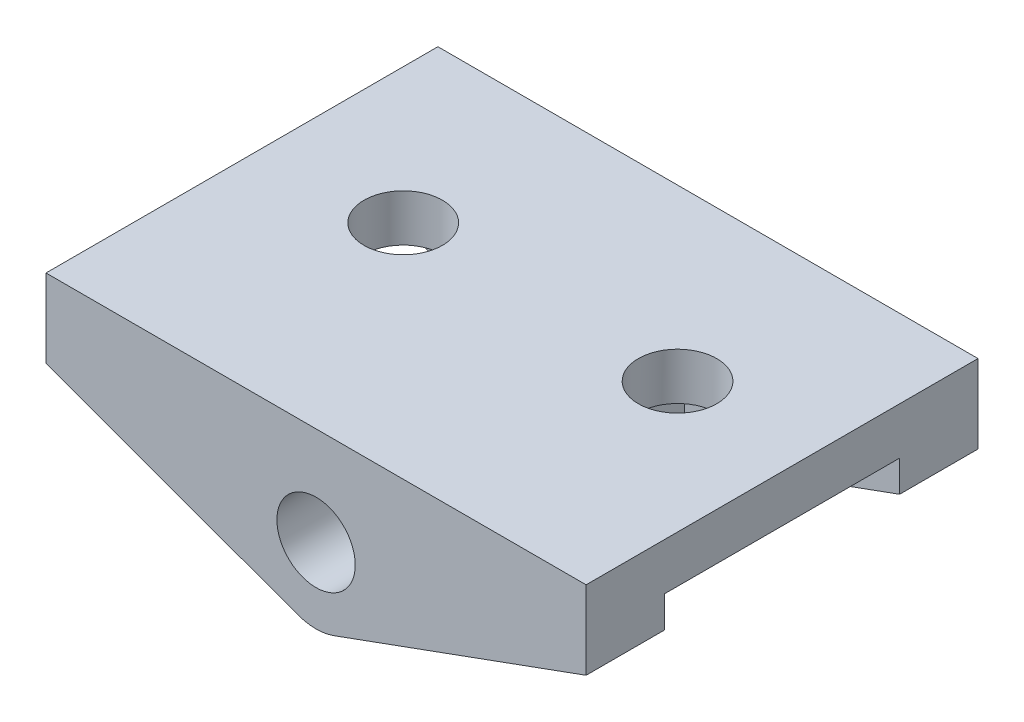
from build123d import *

# Parameters (mm, degrees)
CROQUIS2_R              = 1.5
SALIENTE_EXTRUIR2_DEPTH = 15
CROQUIS3_R              = 1.5
CORTAR_EXTRUIR1_DEPTH   = 7.633866032
CORTAR_EXTRUIR2_DEPTH   = 9
CORTAR_EXTRUIR3_DEPTH   = 9


with BuildPart() as part:
    # Croquis2 → Saliente-Extruir2 (new body)
    with BuildSketch(Plane.XY):
        with BuildLine():
            Line((-0.684040287, -2.751029697), (-10.336618829, 0.762221577))
            Line((-10.336618829, 0.762221577), (-10.336618829, 3.762221577))
            Line((-10.336618829, 3.762221577), (10.336618829, 3.762221577))
            Line((10.336618829, 3.762221577), (10.336618829, 0.762221577))
            Line((10.336618829, 0.762221577), (0.684040287, -2.751029697))
            ThreePointArc((0.684040287, -2.751029697), (0, -2.871644455), (-0.684040287, -2.751029697))
        make_face()
        Circle(CROQUIS2_R, mode=Mode.SUBTRACT)
    extrude(amount=SALIENTE_EXTRUIR2_DEPTH)

    # Croquis3 → Cortar-Extruir1 (cut, through all)
    with BuildSketch(Plane(origin=(0, 3.762221577, 0), x_dir=(1, 0, 0), z_dir=(0, 1, 0))):
        with Locations((5.336618829, -6.5)):
            Circle(CROQUIS3_R)
        with Locations((-5.163381171, -6.5)):
            Circle(CROQUIS3_R)
    extrude(amount=-CORTAR_EXTRUIR1_DEPTH, mode=Mode.SUBTRACT)

    # Croquis4 → Cortar-Extruir2 (cut)
    with BuildSketch(Plane.XY.offset(12)):
        Polygon((10.336618829, 0.762221577), (10.336618829, 1.962221577), (2.103415276, 1.962221577), (2.103415276, -2.234419449), align=None)
    extrude(amount=-CORTAR_EXTRUIR2_DEPTH, mode=Mode.SUBTRACT)

    # Croquis5 → Cortar-Extruir3 (cut)
    with BuildSketch(Plane.XY.offset(12)):
        Polygon((-10.336618829, 0.762221577), (-2.09418657, -2.237778423), (-2.09418657, 1.962221577), (-10.336618829, 1.962221577), align=None)
    extrude(amount=-CORTAR_EXTRUIR3_DEPTH, mode=Mode.SUBTRACT)


solid = part.part
